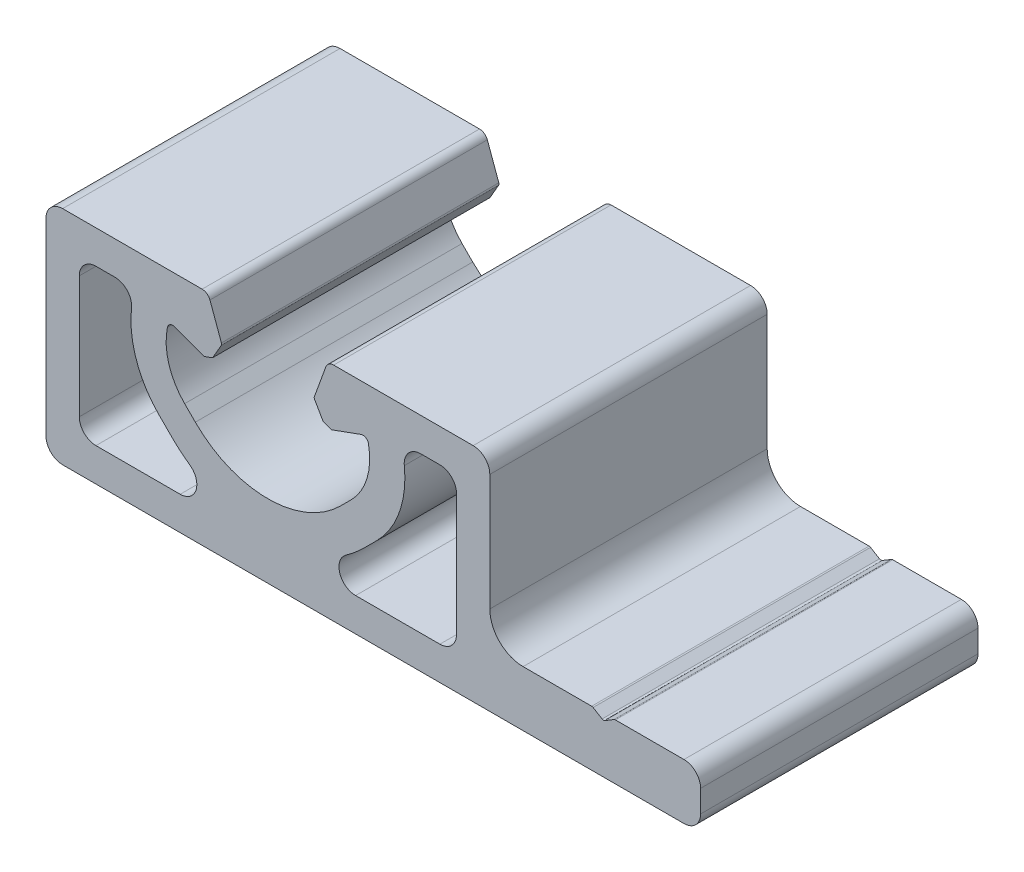
from build123d import *

# Parameters (mm, degrees)
MAIN_EXTRUSION_DEPTH = 25


with BuildPart() as part:
    # Sk Main Extrusion → Main Extrusion (new body)
    with BuildSketch(Plane.XY):
        with BuildLine():
            Line((-4.190076845, 16.671180212), (-5.222054351, 19.506515107))
            ThreePointArc((-5.222054351, 19.506515107), (-5.496641489, 19.864364033), (-5.926823816, 20))
            Line((-5.926823816, 20), (-18.5, 20))
            ThreePointArc((-18.5, 20), (-19.560660172, 19.560660172), (-20, 18.5))
            Line((-20, 18.5), (-20, 1.5))
            ThreePointArc((-20, 1.5), (-19.560660172, 0.439339828), (-18.5, 0))
            Line((-18.5, 0), (37.5, 0))
            ThreePointArc((37.5, 0), (38.560660172, 0.439339828), (39, 1.5))
            Line((39, 1.5), (39, 3.5))
            ThreePointArc((39, 3.5), (38.560660172, 4.560660172), (37.5, 5))
            Line((37.5, 5), (31.319331136, 5))
            ThreePointArc((31.319331136, 5), (31.252521542, 4.990907613), (31.190571617, 4.964291825))
            Line((31.190571617, 4.964291825), (30.378759519, 4.476505905))
            ThreePointArc((30.378759519, 4.476505905), (30.25, 4.44079773), (30.121240481, 4.476505905))
            Line((30.121240481, 4.476505905), (29.309428383, 4.964291825))
            ThreePointArc((29.309428383, 4.964291825), (29.247478458, 4.990907613), (29.180668864, 5))
            Line((29.180668864, 5), (23, 5))
            ThreePointArc((23, 5), (20.878679656, 5.878679656), (20, 8))
            Line((20, 8), (20, 18.5))
            ThreePointArc((20, 18.5), (19.560660172, 19.560660172), (18.5, 20))
            Line((18.5, 20), (5.926823816, 20))
            ThreePointArc((5.926823816, 20), (5.496641489, 19.864364033), (5.222054351, 19.506515107))
            Line((5.222054351, 19.506515107), (4.190076845, 16.671180212))
            ThreePointArc((4.190076845, 16.671180212), (4.175951325, 16.563886241), (4.208493649, 16.460675177))
            Line((4.208493649, 16.460675177), (4.987558066, 15.111296024))
            Line((4.987558066, 15.111296024), (5.718509166, 14.845251581))
            Line((5.718509166, 14.845251581), (8.396186179, 15.81984631))
            ThreePointArc((8.396186179, 15.81984631), (8.811074612, 15.786489799), (9.056960151, 15.450654467))
            ThreePointArc((9.056960151, 15.450654467), (8.933433013, 12.665882372), (7.504160339, 10.272684887))
            Line((7.504160339, 10.272684887), (6.540737726, 9.309262274))
            ThreePointArc((6.540737726, 9.309262274), (0, 6.6), (-6.540737726, 9.309262274))
            Line((-6.540737726, 9.309262274), (-7.504160339, 10.272684887))
            ThreePointArc((-7.504160339, 10.272684887), (-8.933433013, 12.665882372), (-9.056960151, 15.450654467))
            ThreePointArc((-9.056960151, 15.450654467), (-8.811074612, 15.786489799), (-8.396186179, 15.81984631))
            Line((-8.396186179, 15.81984631), (-5.718509166, 14.845251581))
            Line((-5.718509166, 14.845251581), (-4.987558066, 15.111296024))
            Line((-4.987558066, 15.111296024), (-4.208493649, 16.460675177))
            ThreePointArc((-4.208493649, 16.460675177), (-4.175951325, 16.563886241), (-4.190076845, 16.671180212))
        make_face()
        with BuildLine():
            Line((-9.797835979, 8.22371984), (-8.66205807, 7.08794193))
            ThreePointArc((-8.66205807, 7.08794193), (-7.88207258, 6.372610607), (-7.043254789, 5.727272727))
            ThreePointArc((-7.043254789, 5.727272727), (-6.475500267, 4.047732983), (-7.90569415, 3))
            Line((-7.90569415, 3), (-15.5, 3))
            ThreePointArc((-15.5, 3), (-16.560660172, 3.439339828), (-17, 4.5))
            Line((-17, 4.5), (-17, 15.5))
            ThreePointArc((-17, 15.5), (-16.560660172, 16.560660172), (-15.5, 17))
            Line((-15.5, 17), (-13.783837598, 17))
            ThreePointArc((-13.783837598, 17), (-12.666241809, 16.500489706), (-12.292980155, 15.334639535))
            ThreePointArc((-12.292980155, 15.334639535), (-11.855296302, 11.494998738), (-9.797835979, 8.22371984))
        make_face(mode=Mode.SUBTRACT)
        with BuildLine():
            Line((17, 15.5), (17, 4.5))
            ThreePointArc((17, 4.5), (16.560660172, 3.439339828), (15.5, 3))
            Line((15.5, 3), (7.90569415, 3))
            ThreePointArc((7.90569415, 3), (6.475500267, 4.047732983), (7.043254789, 5.727272727))
            ThreePointArc((7.043254789, 5.727272727), (7.88207258, 6.372610607), (8.66205807, 7.08794193))
            Line((8.66205807, 7.08794193), (9.797835979, 8.22371984))
            ThreePointArc((9.797835979, 8.22371984), (11.855296302, 11.494998738), (12.292980155, 15.334639535))
            ThreePointArc((12.292980155, 15.334639535), (12.666241809, 16.500489706), (13.783837598, 17))
            Line((13.783837598, 17), (15.5, 17))
            ThreePointArc((15.5, 17), (16.560660172, 16.560660172), (17, 15.5))
        make_face(mode=Mode.SUBTRACT)
    extrude(amount=-MAIN_EXTRUSION_DEPTH)


solid = part.part
